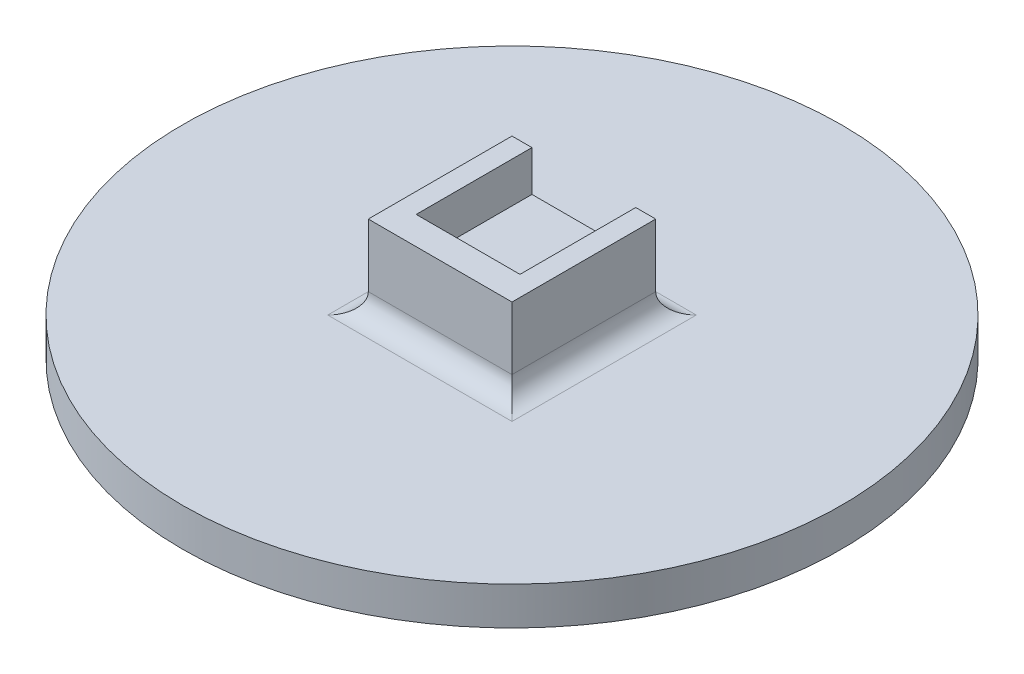
from build123d import *

# Parameters (mm, degrees)
SKETCH1_R           = 41.275
BOSS_EXTRUDE1_DEPTH = 4.7625
SKETCH2_W           = 18
SKETCH2_H           = 18
BOSS_EXTRUDE2_DEPTH = 5.334
FILLET1_R           = 2.54
BOSS_EXTRUDE3_DEPTH = 5.08


with BuildPart() as part:
    # Sketch1 → Boss-Extrude1 (new body)
    with BuildSketch(Plane(origin=(0, 0, 0), x_dir=(1, 0, 0), z_dir=(0, 1, 0))):
        Circle(SKETCH1_R)
    extrude(amount=BOSS_EXTRUDE1_DEPTH)

    # Sketch2 → Boss-Extrude2 (add)
    with BuildSketch(Plane(origin=(0, 4.7625, 0), x_dir=(1, 0, 0), z_dir=(0, 1, 0))):
        Rectangle(SKETCH2_W, SKETCH2_H)
    extrude(amount=BOSS_EXTRUDE2_DEPTH)

    # Fillet1
    fillet1_edges = [part.edges().sort_by_distance(p)[0] for p in [
        (9, 4.7625, 0),
        (0, 4.7625, -9),
        (-9, 4.7625, 0),
        (0, 4.7625, 9),
    ]]
    fillet(fillet1_edges, radius=FILLET1_R)

    # Sketch3 → Boss-Extrude3 (add)
    with BuildSketch(Plane(origin=(0, 10.0965, 0), x_dir=(1, 0, 0), z_dir=(0, 1, 0))):
        Polygon((-9, -9), (9, -9), (9, 9), (6.5, 9), (6.5, -5.5), (-6.5, -5.5), (-6.5, 9), (-9, 9), align=None)
    extrude(amount=BOSS_EXTRUDE3_DEPTH)


solid = part.part
